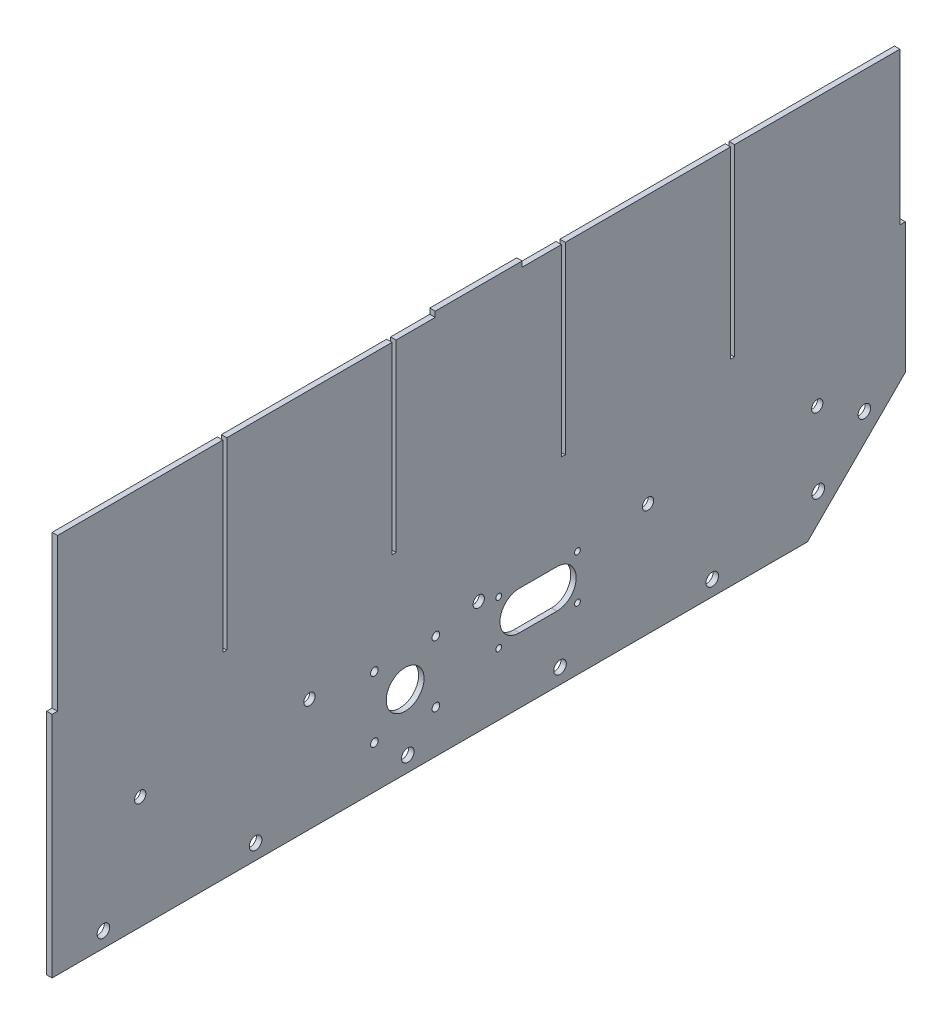
from build123d import *

# Parameters (mm, degrees)
SKETCH1_W            = 498.348
SKETCH1_H            = 165.1
BOSS_EXTRUDE1_DEPTH  = 1.5875
BOSS_EXTRUDE2_DEPTH  = 3.175
CUT_EXTRUDE1_DEPTH   = 4.175
LPATTERN1_COUNT      = 5
LPATTERN1_PITCH      = 88.9
CUT_EXTRUDE2_START   = -4.175
CUT_EXTRUDE2_DEPTH   = 5.175
LPATTERN2_COUNT      = 2
LPATTERN2_PITCH      = 38.1
SKETCH5_W            = 3.175
SKETCH5_H            = 88.9
CUT_EXTRUDE3_DEPTH   = 4.175
SKETCH6_W            = 2.286
SKETCH6_H            = 107.442
CUT_EXTRUDE4_DEPTH   = 4.175
LPATTERN3_COUNT      = 4
LPATTERN3_PITCH      = 98.8568
SKETCH8_W            = 50.8
SKETCH8_H            = 3.175
BOSS_EXTRUDE3_DEPTH  = 3.175
SKETCH9_R            = 11.05
CUT_EXTRUDE5_DEPTH   = 4.175
M6_CLEARANCE_HOLE1_D = 6.6
LPATTERN4_COUNT      = 3
LPATTERN4_PITCH      = 98.8568
LPATTERN4_COL_COUNT  = 3
LPATTERN4_COL_PITCH  = 98.8568
M3_CLEARANCE_HOLE1_D = 3.4
M4_CLEARANCE_HOLE1_D = 4.5
CUT_EXTRUDE6_DEPTH   = 4.175


with BuildPart() as part:
    # Sketch1 → Boss-Extrude1 (new body, symmetric)
    with BuildSketch(Plane(origin=(0, 0, 0), x_dir=(0, 0, -1), z_dir=(1, 0, 0))):
        Rectangle(SKETCH1_W, SKETCH1_H)
    extrude(amount=BOSS_EXTRUDE1_DEPTH, both=True)

    # Sketch2 → Boss-Extrude2 (add)
    with BuildSketch(Plane(origin=(1.5875, 0, 0), x_dir=(0, 0, -1), z_dir=(1, 0, 0))):
        Polygon((192.024, -139.7), (249.174, -82.55), (-249.174, -82.55), (-249.174, -139.7), align=None)
    extrude(amount=-BOSS_EXTRUDE2_DEPTH)

    # Sketch3 → Cut-Extrude1 (cut, through all)
    with BuildSketch(Plane.ZY.offset(1.5875)):
        with BuildLine():
            ThreePointArc((222.877, -130.81), (216.603382579, -128.211382579), (219.202, -134.485))
            Line((219.202, -134.485), (219.202, -130.81))
            Line((219.202, -130.81), (222.877, -130.81))
        make_face()
        with BuildLine():
            Line((219.202, -130.81), (219.202, -134.485))
            ThreePointArc((219.202, -134.485), (221.800617421, -133.408617421), (222.877, -130.81))
            Line((222.877, -130.81), (219.202, -130.81))
        make_face()
    cut_extrude1 = extrude(amount=-CUT_EXTRUDE1_DEPTH, mode=Mode.SUBTRACT)

    # LPattern1: Cut-Extrude1 ×5
    with Locations(*[(0, 0, -i * LPATTERN1_PITCH) for i in range(1, LPATTERN1_COUNT)]):
        add(cut_extrude1, mode=Mode.SUBTRACT)

    # Sketch4 → Cut-Extrude2 (cut)
    with BuildSketch(Plane.ZY.offset(1.5875).offset(CUT_EXTRUDE2_START)):
        with BuildLine():
            ThreePointArc((-194.635179285, -117.249359697), (-199.716540899, -113.854102415), (-200.908796706, -119.847977118))
            Line((-200.908796706, -119.847977118), (-198.310179285, -117.249359697))
            Line((-198.310179285, -117.249359697), (-195.711561864, -119.847977118))
            ThreePointArc((-195.711561864, -119.847977118), (-194.914922003, -118.655721311), (-194.635179285, -117.249359697))
        make_face()
        with BuildLine():
            Line((-198.310179285, -117.249359697), (-200.908796706, -119.847977118))
            ThreePointArc((-200.908796706, -119.847977118), (-198.310179285, -120.924359697), (-195.711561864, -119.847977118))
            Line((-195.711561864, -119.847977118), (-198.310179285, -117.249359697))
        make_face()
    cut_extrude2 = extrude(amount=CUT_EXTRUDE2_DEPTH, mode=Mode.SUBTRACT)

    # LPattern2: Cut-Extrude2 ×2
    with Locations(*[Vector(0, 0.707106781, -0.707106781) * (i * LPATTERN2_PITCH) for i in range(1, LPATTERN2_COUNT)]):
        add(cut_extrude2, mode=Mode.SUBTRACT)

    # Sketch5 → Cut-Extrude3 (cut, through all)
    with BuildSketch(Plane(origin=(1.5875, 0, 0), x_dir=(0, 0, -1), z_dir=(1, 0, 0))):
        with Locations((247.5865, 38.1)):
            Rectangle(SKETCH5_W, SKETCH5_H)
        with Locations((-247.5865, 38.1)):
            Rectangle(SKETCH5_W, SKETCH5_H)
    extrude(amount=-CUT_EXTRUDE3_DEPTH, mode=Mode.SUBTRACT)

    # Sketch6 → Cut-Extrude4 (cut, through all)
    with BuildSketch(Plane(origin=(1.5875, 0, 0), x_dir=(0, 0, -1), z_dir=(1, 0, 0))):
        with Locations((148.2852, 28.829)):
            Rectangle(SKETCH6_W, SKETCH6_H)
    cut_extrude4 = extrude(amount=-CUT_EXTRUDE4_DEPTH, mode=Mode.SUBTRACT)

    # LPattern3: Cut-Extrude4 ×4
    with Locations(*[(0, 0, i * LPATTERN3_PITCH) for i in range(1, LPATTERN3_COUNT)]):
        add(cut_extrude4, mode=Mode.SUBTRACT)

    # Sketch8 → Boss-Extrude3 (add)
    with BuildSketch(Plane(origin=(1.5875, 0, 0), x_dir=(0, 0, -1), z_dir=(1, 0, 0))):
        with Locations((0, 84.1375)):
            Rectangle(SKETCH8_W, SKETCH8_H)
    extrude(amount=-BOSS_EXTRUDE3_DEPTH)

    # Sketch9 → Cut-Extrude5 (cut, through all)
    with BuildSketch(Plane(origin=(1.5875, 0, 0), x_dir=(0, 0, -1), z_dir=(1, 0, 0))):
        with Locations((-42.9768, -96.7994)):
            Circle(SKETCH9_R)
    extrude(amount=-CUT_EXTRUDE5_DEPTH, mode=Mode.SUBTRACT)

    # M6 Clearance Hole1 (through all)
    with Locations(Plane(origin=(1.5875, 0, 0), x_dir=(0, 0, -1), z_dir=(1, 0, 0))):
        with Locations((0, -73.8124)):
            m6_clearance_hole1 = Hole(M6_CLEARANCE_HOLE1_D / 2)

    # LPattern4: M6 Clearance Hole1 ×3
    with Locations(*[(0, 0, i * LPATTERN4_PITCH) for i in range(1, LPATTERN4_COUNT)]):
        add(m6_clearance_hole1, mode=Mode.SUBTRACT)

    # LPattern4 col: M6 Clearance Hole1 ×3
    with Locations(*[(0, 0, -i * LPATTERN4_COL_PITCH) for i in range(1, LPATTERN4_COL_COUNT)]):
        add(m6_clearance_hole1, mode=Mode.SUBTRACT)

    # M3 Clearance Hole1 (through all)
    with Locations(Plane(origin=(1.5875, 0, 0), x_dir=(0, 0, -1), z_dir=(1, 0, 0))):
        with Locations((11.674, -77.315), (11.674, -103.315), (57.674, -103.315), (57.674, -77.315)):
            Hole(M3_CLEARANCE_HOLE1_D / 2)

    # M4 Clearance Hole1 (through all)
    with Locations(Plane(origin=(1.5875, 0, 0), x_dir=(0, 0, -1), z_dir=(1, 0, 0))):
        with Locations((-25.0163, -78.8389), (-60.9373, -78.8389), (-60.9373, -114.7599), (-25.0163, -114.7599)):
            Hole(M4_CLEARANCE_HOLE1_D / 2)

    # Sketch14 → Cut-Extrude6 (cut, through all)
    with BuildSketch(Plane(origin=(1.5875, 0, 0), x_dir=(0, 0, -1), z_dir=(1, 0, 0))):
        with BuildLine():
            Line((45.674, -101.565), (23.674, -101.565))
            ThreePointArc((23.674, -101.565), (12.424, -90.315), (23.674, -79.065))
            Line((23.674, -79.065), (45.674, -79.065))
            ThreePointArc((45.674, -79.065), (56.924, -90.315), (45.674, -101.565))
        make_face()
    extrude(amount=-CUT_EXTRUDE6_DEPTH, mode=Mode.SUBTRACT)


solid = part.part
